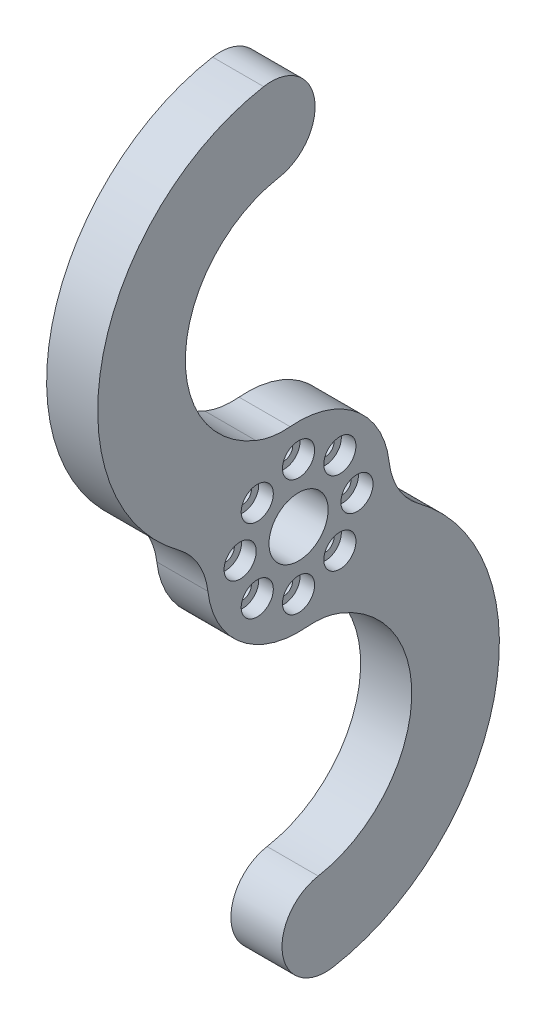
from build123d import *

# Parameters (mm, degrees)
SKETCH1_R                      = 4.05
BOSS_EXTRUDE1_DEPTH            = 7
FILLET1_R                      = 10
CBORE_FOR_M2_SHCS1_D           = 2.4
CBORE_FOR_M2_SHCS1_CBORE_D     = 4.4
CBORE_FOR_M2_SHCS1_CBORE_DEPTH = 2


with BuildPart() as part:
    # Sketch1 → Boss-Extrude1 (new body)
    with BuildSketch(Plane(origin=(0, 0, 0), x_dir=(0, 0, -1), z_dir=(1, 0, 0))):
        with BuildLine():
            ThreePointArc((-2.618193655, 12.222727273), (-15.499955296, 27.462773314), (-2.691546754, 42.764520172))
            ThreePointArc((-2.691546754, 42.764520172), (2.175410698, 49.715255756), (-4.775324886, 54.582213208))
            ThreePointArc((-4.775324886, 54.582213208), (-27.223172657, 31.392154992), (-12.172889367, 2.840909091))
            ThreePointArc((-12.172889367, 2.840909091), (-8.919155658, -8.757777249), (2.618193655, -12.222727273))
            ThreePointArc((2.618193655, -12.222727273), (15.499955296, -27.462773314), (2.691546754, -42.764520172))
            ThreePointArc((2.691546754, -42.764520172), (-2.175410698, -49.715255756), (4.775324886, -54.582213208))
            ThreePointArc((4.775324886, -54.582213208), (27.223172657, -31.392154992), (12.172889367, -2.840909091))
            ThreePointArc((12.172889367, -2.840909091), (8.919155658, 8.757777249), (-2.618193655, 12.222727273))
        make_face()
        Circle(SKETCH1_R, mode=Mode.SUBTRACT)
    extrude(amount=BOSS_EXTRUDE1_DEPTH)

    # Fillet1
    fillet1_edges = [part.edges().sort_by_distance(p)[0] for p in [
        (3.5, -2.840909091, -12.172889367),
        (3.5, -12.222727273, -2.618193655),
        (3.5, 2.840909091, 12.172889367),
        (3.5, 12.222727273, 2.618193655),
    ]]
    fillet(fillet1_edges, radius=FILLET1_R)

    # CBORE for M2 SHCS1 (through all)
    with Locations(Plane(origin=(7, 0, 0), x_dir=(0, 0, -1), z_dir=(1, 0, 0))):
        with Locations((-5.656854249, 5.656854249), (0, 8), (5.656854249, 5.656854249), (8, 0), (5.656854249, -5.656854249), (0, -8), (-5.656854249, -5.656854249), (-8, 0)):
            CounterBoreHole(CBORE_FOR_M2_SHCS1_D / 2, CBORE_FOR_M2_SHCS1_CBORE_D / 2, CBORE_FOR_M2_SHCS1_CBORE_DEPTH)


solid = part.part
